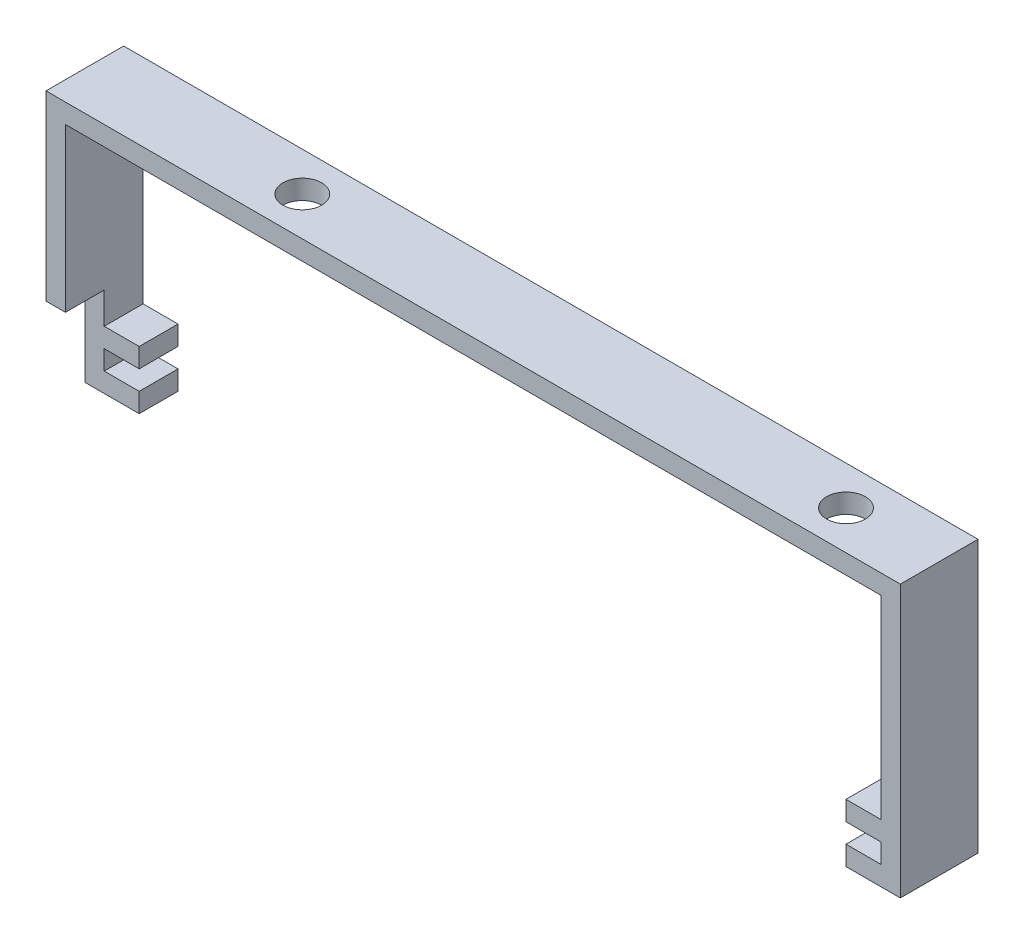
from build123d import *

# Parameters (mm, degrees)
BOSS_EXTRUDE1_DEPTH = 10
SKETCH2_W           = 7.883034156
SKETCH2_H           = 11.550106774
CUT_EXTRUDE1_DEPTH  = 5
SKETCH3_R           = 2.5
CUT_EXTRUDE2_DEPTH  = 3


with BuildPart() as part:
    # Sketch1 → Boss-Extrude1 (new body)
    with BuildSketch(Plane.XY):
        Polygon((2.5, -30), (2.5, -32.5), (7, -32.5), (7, -35), (0, -35), (0, -32.5), (0, -2.5), (0, 0), (110, 0), (110, -2.5), (110, -32.5), (110, -35), (103, -35), (103, -32.5), (107.5, -32.5), (107.5, -30), (103, -30), (103, -27.5), (107.5, -27.5), (107.5, -2.5), (2.5, -2.5), (2.5, -27.5), (7, -27.5), (7, -30), align=None)
    extrude(amount=BOSS_EXTRUDE1_DEPTH)

    # Sketch2 → Cut-Extrude1 (cut)
    with BuildSketch(Plane.XY.offset(10)):
        with Locations((3.941517078, -29.224946613)):
            Rectangle(SKETCH2_W, SKETCH2_H)
    extrude(amount=-CUT_EXTRUDE1_DEPTH, mode=Mode.SUBTRACT)

    # Sketch3 → Cut-Extrude2 (cut)
    with BuildSketch(Plane(origin=(0, 0, 0), x_dir=(1, 0, 0), z_dir=(0, 1, 0))):
        with Locations((98, -5)):
            Circle(SKETCH3_R)
        with Locations((28, -5)):
            Circle(SKETCH3_R)
    extrude(amount=-CUT_EXTRUDE2_DEPTH, mode=Mode.SUBTRACT)


solid = part.part
